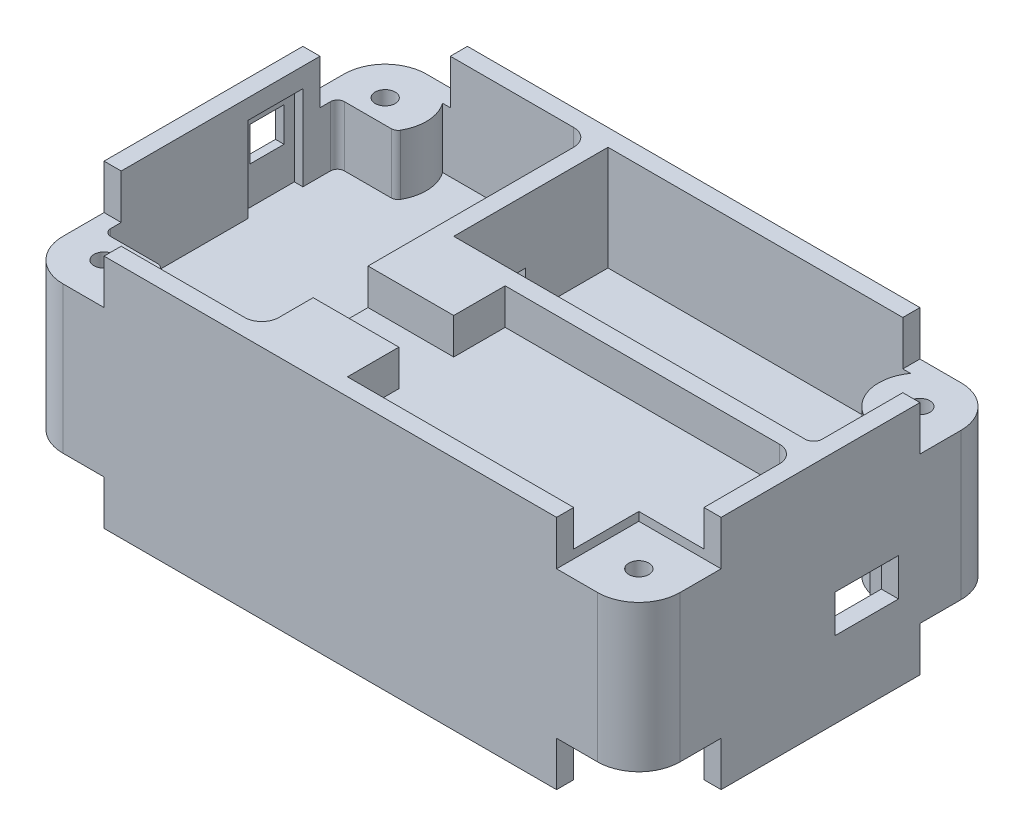
from build123d import *

# Parameters (mm, degrees)
SKETCH1_W                 = 114.3
SKETCH1_H                 = 67.31
SKETCH1_W_2               = 107.95
SKETCH1_H_2               = 60.96
BOSS_EXTRUDE1_DEPTH       = 16.764
BOSS_EXTRUDE1_DEPTH_BACK  = 26.924
FILLET2_R                 = 7.62
BOSS_EXTRUDE3_START       = -26.924
BOSS_EXTRUDE3_DEPTH       = 43.688
BOSS_EXTRUDE4_START       = -26.924
BOSS_EXTRUDE4_DEPTH       = 43.688
BOSS_EXTRUDE5_START       = -26.924
BOSS_EXTRUDE5_DEPTH       = 43.688
BOSS_EXTRUDE6_START       = -26.924
BOSS_EXTRUDE6_DEPTH       = 43.688
BOSS_EXTRUDE7_DEPTH       = 19.3675
BOSS_EXTRUDE8_DEPTH       = 3.175
BOSS_EXTRUDE9_DEPTH       = 3.175
CUT_EXTRUDE7_REACH        = 36.925
SKETCH19_R                = 3.175
SKETCH25_W                = 34.6075
SKETCH25_H                = 3.175
BOSS_EXTRUDE14_DEPTH      = 3.175
SKETCH30_W                = 3.175
SKETCH30_H                = 22.86
BOSS_EXTRUDE22_DEPTH      = 1.5875
BOSS_EXTRUDE22_DEPTH_BACK = 1.5875
SKETCH31_W                = 31.75
SKETCH31_H                = 3.175
BOSS_EXTRUDE23_DEPTH      = 1.5875
SKETCH32_W                = 8.89
SKETCH32_H                = 29.21
BOSS_EXTRUDE24_DEPTH      = 3.175
BOSS_EXTRUDE27_DEPTH      = 3.175
SKETCH38_W                = 13.6525
SKETCH38_H                = 9.525
BOSS_EXTRUDE28_DEPTH      = 6.6675
SKETCH39_W                = 13.6525
SKETCH39_H                = 9.525
BOSS_EXTRUDE29_DEPTH      = 6.6675
FILLET17_R                = 3.175
FILLET18_R                = 1.5875
FILLET22_R                = 3.175
FILLET29_R                = 3.175
SKETCH44_W                = 19.685
SKETCH44_H                = 1.7018
CUT_EXTRUDE13_DEPTH       = 2.54
CUT_EXTRUDE13_DEPTH_BACK  = 1.5875
CUT_EXTRUDE15_REACH       = 116.3
SKETCH46_W                = 11.7475
SKETCH46_H                = 6.985
BOSS_EXTRUDE31_REACH      = 26.13
SKETCH47_W                = 1.5875
SKETCH47_H                = 19.685
SKETCH55_W                = 8.89
SKETCH55_H                = 9.525
BOSS_EXTRUDE32_DEPTH      = 9.8425
SKETCH56_W                = 34.6075
SKETCH56_H                = 3.96875
CUT_EXTRUDE21_DEPTH       = 6.35
SKETCH61_R                = 7.62
BOSS_EXTRUDE35_DEPTH      = 43.688
BOSS_EXTRUDE37_START      = -1.5875
SKETCH63_W                = 6.0325
SKETCH63_H                = 2.54
BOSS_EXTRUDE37_DEPTH      = 21.1455
SKETCH64_W                = 10.16
SKETCH64_H                = 6.35
BOSS_EXTRUDE38_DEPTH      = 3.175
SKETCH65_W                = 6.35
SKETCH65_H                = 6.35
BOSS_EXTRUDE39_DEPTH      = 3.175
SKETCH66_W                = 15.24
SKETCH66_H                = 15.24
CUT_EXTRUDE23_DEPTH       = 3.175
SKETCH67_W                = 15.24
SKETCH67_H                = 15.24
CUT_EXTRUDE24_DEPTH       = 3.175
SKETCH68_W                = 15.24
SKETCH68_H                = 15.24
CUT_EXTRUDE25_DEPTH       = 3.175
SKETCH69_W                = 15.24
SKETCH69_H                = 15.24
CUT_EXTRUDE26_DEPTH       = 3.175
SKETCH70_W                = 15.24
SKETCH70_H                = 15.24
CUT_EXTRUDE27_DEPTH       = 3.175
SKETCH71_W                = 15.24
SKETCH71_H                = 15.24
CUT_EXTRUDE28_DEPTH       = 3.175
SKETCH72_W                = 15.24
SKETCH72_H                = 15.24
CUT_EXTRUDE29_DEPTH       = 3.175
SKETCH73_W                = 15.24
SKETCH73_H                = 15.24
CUT_EXTRUDE30_DEPTH       = 3.175
SKETCH74_R                = 1.8542
CUT_EXTRUDE31_DEPTH       = 41.513
BOSS_EXTRUDE40_DEPTH      = 8.89
SKETCH76_W                = 19.3675
SKETCH76_H                = 29.21
CUT_EXTRUDE32_DEPTH       = 6.6675
SKETCH80_W                = 12.7
SKETCH80_H                = 9.525
BOSS_EXTRUDE41_DEPTH      = 6.6675
SKETCH81_W                = 12.7
SKETCH81_H                = 9.525
BOSS_EXTRUDE42_DEPTH      = 6.6675
SKETCH82_W                = 10.16
SKETCH82_H                = 15.748
CUT_EXTRUDE34_DEPTH       = 1.5875
SKETCH83_W                = 6.35
SKETCH83_H                = 6.35
CUT_EXTRUDE35_DEPTH       = 2.5875
SKETCH88_W                = 5.08
SKETCH88_H                = 29.21
BOSS_EXTRUDE43_DEPTH      = 4.365625
FILLET32_R                = 3.175
FILLET33_R                = 3.175
SKETCH89_W                = 12.7
SKETCH89_H                = 43.2816
CUT_EXTRUDE40_DEPTH       = 16.1925
FILLET34_R                = 1.27
FILLET35_R                = 1.27
CUT_EXTRUDE41_REACH       = 67.405
SKETCH90_R                = 3.33375
SKETCH91_W                = 34.6075
SKETCH91_H                = 3.96875
CUT_EXTRUDE42_DEPTH       = 3.175
SKETCH92_W                = 6.35
SKETCH92_H                = 3.556
BOSS_EXTRUDE44_DEPTH      = 5.08
SKETCH94_W                = 12.7
SKETCH94_H                = 43.2816
CUT_EXTRUDE43_DEPTH       = 17.9705
FILLET36_R                = 1.27
SKETCH95_W                = 7.62
SKETCH95_H                = 7.62
CUT_EXTRUDE44_DEPTH       = 11.43
SKETCH97_W                = 7.62
SKETCH97_H                = 7.62
CUT_EXTRUDE45_DEPTH       = 11.43
SKETCH98_W                = 15.24
SKETCH98_H                = 15.24
CUT_EXTRUDE46_DEPTH       = 5.08
SKETCH99_W                = 15.24
SKETCH99_H                = 15.24
CUT_EXTRUDE47_DEPTH       = 5.08
SKETCH100_W               = 15.24
SKETCH100_H               = 15.24
CUT_EXTRUDE50_DEPTH       = 5.08
SKETCH102_W               = 15.24
SKETCH102_H               = 15.24
CUT_EXTRUDE51_DEPTH       = 5.08
SKETCH103_W               = 15.24
SKETCH103_H               = 15.24
CUT_EXTRUDE52_DEPTH       = 5.08


with BuildPart() as part:
    # Sketch1 → Boss-Extrude1 (new body, two sides)
    with BuildSketch(Plane(origin=(0, 0, 0), x_dir=(1, 0, 0), z_dir=(0, 1, 0))) as boss_extrude1_sk:
        Rectangle(SKETCH1_W, SKETCH1_H)
        Rectangle(SKETCH1_W_2, SKETCH1_H_2, mode=Mode.SUBTRACT)
    extrude(amount=BOSS_EXTRUDE1_DEPTH)
    extrude(boss_extrude1_sk.sketch, amount=-BOSS_EXTRUDE1_DEPTH_BACK)

    # Fillet2
    fillet2_edges = [part.edges().sort_by_distance(p)[0] for p in [
        (57.15, -5.08, 33.655),
        (-57.15, -5.08, 33.655),
        (-57.15, -5.08, -33.655),
        (57.15, -5.08, -33.655),
    ]]
    fillet(fillet2_edges, radius=FILLET2_R)

    # Sketch3 → Boss-Extrude3 (add)
    with BuildSketch(Plane(origin=(0, 0, 0), x_dir=(1, 0, 0), z_dir=(0, 1, 0)).offset(BOSS_EXTRUDE3_START)):
        Polygon((-53.975, 20.32), (-43.815, 30.48), (-53.975, 30.48), align=None)
    extrude(amount=BOSS_EXTRUDE3_DEPTH)

    # Sketch5 → Boss-Extrude4 (add)
    with BuildSketch(Plane(origin=(0, 0, 0), x_dir=(1, 0, 0), z_dir=(0, 1, 0)).offset(BOSS_EXTRUDE4_START)):
        Polygon((-53.975, -30.48), (-53.975, -20.32), (-43.815, -30.48), align=None)
    extrude(amount=BOSS_EXTRUDE4_DEPTH)

    # Sketch6 → Boss-Extrude5 (add)
    with BuildSketch(Plane(origin=(0, 0, 0), x_dir=(1, 0, 0), z_dir=(0, 1, 0)).offset(BOSS_EXTRUDE5_START)):
        Polygon((53.975, -20.32), (43.815, -30.48), (53.975, -30.48), align=None)
    extrude(amount=BOSS_EXTRUDE5_DEPTH)

    # Sketch7 → Boss-Extrude6 (add)
    with BuildSketch(Plane(origin=(0, 0, 0), x_dir=(1, 0, 0), z_dir=(0, 1, 0)).offset(BOSS_EXTRUDE6_START)):
        Polygon((53.975, 30.48), (43.815, 30.48), (53.975, 20.32), align=None)
    extrude(amount=BOSS_EXTRUDE6_DEPTH)

    # Sketch12 → Boss-Extrude7 (add)
    with BuildSketch(Plane(origin=(0, -2.6035, 0), x_dir=(1, 0, 0), z_dir=(0, 1, 0))):
        Polygon((53.975, 1.905), (-12.7, 1.905), (-12.7, 30.48), (-15.875, 30.48), (-15.875, -1.27), (53.975, -1.27), align=None)
    extrude(amount=BOSS_EXTRUDE7_DEPTH)

    # Sketch13 → Boss-Extrude8 (add)
    with BuildSketch(Plane(origin=(0, -2.6035, 0), x_dir=(1, 0, 0), z_dir=(0, 1, 0))):
        with BuildLine():
            Line((-15.875, 30.48), (-15.875, -1.27))
            Line((-15.875, -1.27), (53.975, -1.27))
            Line((53.975, -1.27), (53.975, 17.163692655))
            ThreePointArc((53.975, 17.163692655), (53.394962038, 20.079740409), (51.743153673, 22.551846327))
            Line((51.743153673, 22.551846327), (46.046846327, 28.248153673))
            ThreePointArc((46.046846327, 28.248153673), (43.574740409, 29.899962038), (40.658692655, 30.48))
            Line((40.658692655, 30.48), (-15.875, 30.48))
        make_face()
    extrude(amount=-BOSS_EXTRUDE8_DEPTH)

    # Sketch16 → Boss-Extrude9 (add)
    with BuildSketch(Plane.XZ.offset(5.7785)):
        with BuildLine():
            Line((-15.875, -30.48), (-15.875, 30.48))
            Line((-15.875, 30.48), (-40.658692655, 30.48))
            ThreePointArc((-40.658692655, 30.48), (-43.574740409, 29.899962038), (-46.046846327, 28.248153673))
            Line((-46.046846327, 28.248153673), (-51.743153673, 22.551846327))
            ThreePointArc((-51.743153673, 22.551846327), (-53.394962038, 20.079740409), (-53.975, 17.163692655))
            Line((-53.975, 17.163692655), (-53.975, -17.163692655))
            ThreePointArc((-53.975, -17.163692655), (-53.394962038, -20.079740409), (-51.743153673, -22.551846327))
            Line((-51.743153673, -22.551846327), (-46.046846327, -28.248153673))
            ThreePointArc((-46.046846327, -28.248153673), (-43.574740409, -29.899962038), (-40.658692655, -30.48))
            Line((-40.658692655, -30.48), (-15.875, -30.48))
        make_face()
    extrude(amount=-BOSS_EXTRUDE9_DEPTH)

    # Sketch19 → Cut-Extrude7 (cut, up to next)
    with BuildSketch(Plane.XY.offset(1.27), mode=Mode.PRIVATE) as cut_extrude7_sk1:
        with Locations((41.275, 1.524)):
            Circle(SKETCH19_R)
    cut_extrude7_tool1 = extrude(cut_extrude7_sk1.sketch, amount=-CUT_EXTRUDE7_REACH, mode=Mode.PRIVATE) & part.part
    add(cut_extrude7_tool1.solids().sort_by_distance((41.275, 1.524, 1.27))[0], mode=Mode.SUBTRACT)

    # Sketch25 → Boss-Extrude14 (add)
    with BuildSketch(Plane.XY.offset(1.27)):
        with Locations((36.67125, -5.7785)):
            Rectangle(SKETCH25_W, SKETCH25_H)
    extrude(amount=BOSS_EXTRUDE14_DEPTH)

    # Sketch30 → Boss-Extrude22 (add, two sides)
    with BuildSketch(Plane.XZ.offset(5.7785)) as boss_extrude22_sk:
        with Locations((17.78, -6.985)):
            Rectangle(SKETCH30_W, SKETCH30_H)
    extrude(amount=BOSS_EXTRUDE22_DEPTH)
    extrude(boss_extrude22_sk.sketch, amount=-BOSS_EXTRUDE22_DEPTH_BACK)

    # Sketch31 → Boss-Extrude23 (add)
    with BuildSketch(Plane.XZ.offset(5.7785)):
        with Locations((32.0675, -20.0025)):
            Rectangle(SKETCH31_W, SKETCH31_H)
    extrude(amount=BOSS_EXTRUDE23_DEPTH)

    # Sketch32 → Boss-Extrude24 (add)
    with BuildSketch(Plane.XZ.offset(5.7785)):
        with Locations((-11.43, 15.875)):
            Rectangle(SKETCH32_W, SKETCH32_H)
    extrude(amount=-BOSS_EXTRUDE24_DEPTH)

    # Sketch37 → Boss-Extrude27 (add)
    with BuildSketch(Plane(origin=(0, 10.0965, 0), x_dir=(1, 0, 0), z_dir=(0, 1, 0))):
        Polygon((-6.985, -1.27), (-6.985, -30.48), (43.815, -30.48), (53.975, -20.32), (53.975, -1.27), align=None)
    extrude(amount=-BOSS_EXTRUDE27_DEPTH)

    # Sketch38 → Boss-Extrude28 (add)
    with BuildSketch(Plane(origin=(0, 10.0965, 0), x_dir=(1, 0, 0), z_dir=(0, 1, 0))):
        with Locations((-0.15875, -6.0325)):
            Rectangle(SKETCH38_W, SKETCH38_H)
    extrude(amount=BOSS_EXTRUDE28_DEPTH)

    # Sketch39 → Boss-Extrude29 (add)
    with BuildSketch(Plane(origin=(0, 10.0965, 0), x_dir=(1, 0, 0), z_dir=(0, 1, 0))):
        with Locations((-0.15875, -25.7175)):
            Rectangle(SKETCH39_W, SKETCH39_H)
    extrude(amount=BOSS_EXTRUDE29_DEPTH)

    # Fillet17
    fillet17_edges = [part.edges().sort_by_distance(p)[0] for p in [
        (53.975, 13.43025, 1.27),
    ]]
    fillet(fillet17_edges, radius=FILLET17_R)

    # Fillet18
    fillet18_edges = [part.edges().sort_by_distance(p)[0] for p in [
        (53.975, 7.08025, -1.905),
    ]]
    fillet(fillet18_edges, radius=FILLET18_R)

    # Fillet22
    fillet22_edges = [part.edges().sort_by_distance(p)[0] for p in [
        (-6.985, -4.191, 30.48),
        (-6.985, -4.191, 1.27),
    ]]
    fillet(fillet22_edges, radius=FILLET22_R)

    # Fillet29
    fillet29_edges = [part.edges().sort_by_distance(p)[0] for p in [
        (-15.875, 7.08025, -30.48),
    ]]
    fillet(fillet29_edges, radius=FILLET29_R)

    # Sketch44 → Cut-Extrude13 (cut, two sides)
    with BuildSketch(Plane.ZY.offset(-53.975)) as cut_extrude13_sk:
        with Locations((-8.5725, -6.6294)):
            Rectangle(SKETCH44_W, SKETCH44_H)
    extrude(amount=CUT_EXTRUDE13_DEPTH, mode=Mode.SUBTRACT)
    extrude(cut_extrude13_sk.sketch, amount=-CUT_EXTRUDE13_DEPTH_BACK, mode=Mode.SUBTRACT)

    # Sketch46 → Cut-Extrude15 (cut, up to next)
    with BuildSketch(Plane(origin=(57.15, 0, 0), x_dir=(0, 0, -1), z_dir=(1, 0, 0)), mode=Mode.PRIVATE) as cut_extrude15_sk1:
        with Locations((8.5725, -9.271)):
            Rectangle(SKETCH46_W, SKETCH46_H)
    cut_extrude15_tool1 = extrude(cut_extrude15_sk1.sketch, amount=-CUT_EXTRUDE15_REACH, mode=Mode.PRIVATE) & part.part
    add(cut_extrude15_tool1.solids().sort_by_distance((57.15, -9.271, -8.5725))[0], mode=Mode.SUBTRACT)

    # Sketch47 → Boss-Extrude31 (add, up to next)
    with BuildSketch(Plane.XZ.offset(7.366), mode=Mode.PRIVATE) as boss_extrude31_sk1:
        with Locations((20.16125, -8.5725)):
            Rectangle(SKETCH47_W, SKETCH47_H)
    boss_extrude31_tool1 = extrude(boss_extrude31_sk1.sketch, amount=-BOSS_EXTRUDE31_REACH, mode=Mode.PRIVATE) - part.part
    add(boss_extrude31_tool1.solids().sort_by_distance((20.16125, -7.366, -8.5725))[0])

    # Sketch55 → Boss-Extrude32 (add)
    with BuildSketch(Plane(origin=(0, 16.764, 0), x_dir=(1, 0, 0), z_dir=(0, 1, 0))):
        with Locations((-11.43, -6.0325)):
            Rectangle(SKETCH55_W, SKETCH55_H)
    extrude(amount=-BOSS_EXTRUDE32_DEPTH)

    # Sketch56 → Cut-Extrude21 (cut)
    with BuildSketch(Plane.XZ.offset(5.7785)):
        with Locations((38.25875, -0.714375)):
            Rectangle(SKETCH56_W, SKETCH56_H)
    extrude(amount=-CUT_EXTRUDE21_DEPTH, mode=Mode.SUBTRACT)

    # Sketch61 → Boss-Extrude35 (add)
    with BuildSketch(Plane.XZ.offset(26.924)):
        with Locations((49.53, -26.035)):
            Circle(SKETCH61_R)
        with Locations((49.53, 26.035)):
            Circle(SKETCH61_R)
        with Locations((-49.53, 26.035)):
            Circle(SKETCH61_R)
        with Locations((-49.53, -26.035)):
            Circle(SKETCH61_R)
    extrude(amount=-BOSS_EXTRUDE35_DEPTH)

    # Sketch63 → Boss-Extrude37 (add)
    with BuildSketch(Plane.XZ.offset(7.366).offset(BOSS_EXTRUDE37_START)):
        with Locations((50.95875, -19.685)):
            Rectangle(SKETCH63_W, SKETCH63_H)
    extrude(amount=BOSS_EXTRUDE37_DEPTH)

    # Sketch64 → Boss-Extrude38 (add)
    with BuildSketch(Plane(origin=(0, -2.6035, 0), x_dir=(1, 0, 0), z_dir=(0, 1, 0))):
        with Locations((38.260785591, 27.305)):
            Rectangle(SKETCH64_W, SKETCH64_H)
    extrude(amount=-BOSS_EXTRUDE38_DEPTH)

    # Sketch65 → Boss-Extrude39 (add)
    with BuildSketch(Plane.XZ.offset(5.7785)):
        with Locations((-42.545, 27.305)):
            Rectangle(SKETCH65_W, SKETCH65_H)
        with Locations((-50.8, 17.78)):
            Rectangle(SKETCH65_W, SKETCH65_H)
        with Locations((-50.8, -17.78)):
            Rectangle(SKETCH65_W, SKETCH65_H)
        with Locations((-42.545, -27.305)):
            Rectangle(SKETCH65_W, SKETCH65_H)
    extrude(amount=-BOSS_EXTRUDE39_DEPTH)

    # Sketch66 → Cut-Extrude23 (cut)
    with BuildSketch(Plane.XZ.offset(26.924)):
        with Locations((-49.53, -26.035)):
            Rectangle(SKETCH66_W, SKETCH66_H)
    extrude(amount=-CUT_EXTRUDE23_DEPTH, mode=Mode.SUBTRACT)

    # Sketch67 → Cut-Extrude24 (cut)
    with BuildSketch(Plane.XZ.offset(26.924)):
        with Locations((-49.53, 26.035)):
            Rectangle(SKETCH67_W, SKETCH67_H)
    extrude(amount=-CUT_EXTRUDE24_DEPTH, mode=Mode.SUBTRACT)

    # Sketch68 → Cut-Extrude25 (cut)
    with BuildSketch(Plane.XZ.offset(26.924)):
        with Locations((49.53, -26.035)):
            Rectangle(SKETCH68_W, SKETCH68_H)
    extrude(amount=-CUT_EXTRUDE25_DEPTH, mode=Mode.SUBTRACT)

    # Sketch69 → Cut-Extrude26 (cut)
    with BuildSketch(Plane.XZ.offset(26.924)):
        with Locations((49.53, 26.035)):
            Rectangle(SKETCH69_W, SKETCH69_H)
    extrude(amount=-CUT_EXTRUDE26_DEPTH, mode=Mode.SUBTRACT)

    # Sketch70 → Cut-Extrude27 (cut)
    with BuildSketch(Plane(origin=(0, 16.764, 0), x_dir=(1, 0, 0), z_dir=(0, 1, 0))):
        with Locations((-49.53, 26.035)):
            Rectangle(SKETCH70_W, SKETCH70_H)
    extrude(amount=-CUT_EXTRUDE27_DEPTH, mode=Mode.SUBTRACT)

    # Sketch71 → Cut-Extrude28 (cut)
    with BuildSketch(Plane(origin=(0, 16.764, 0), x_dir=(1, 0, 0), z_dir=(0, 1, 0))):
        with Locations((-49.53, -26.035)):
            Rectangle(SKETCH71_W, SKETCH71_H)
    extrude(amount=-CUT_EXTRUDE28_DEPTH, mode=Mode.SUBTRACT)

    # Sketch72 → Cut-Extrude29 (cut)
    with BuildSketch(Plane(origin=(0, 16.764, 0), x_dir=(1, 0, 0), z_dir=(0, 1, 0))):
        with Locations((49.53, -26.035)):
            Rectangle(SKETCH72_W, SKETCH72_H)
    extrude(amount=-CUT_EXTRUDE29_DEPTH, mode=Mode.SUBTRACT)

    # Sketch73 → Cut-Extrude30 (cut)
    with BuildSketch(Plane(origin=(0, 16.764, 0), x_dir=(1, 0, 0), z_dir=(0, 1, 0))):
        with Locations((49.53, 26.035)):
            Rectangle(SKETCH73_W, SKETCH73_H)
    extrude(amount=-CUT_EXTRUDE30_DEPTH, mode=Mode.SUBTRACT)

    # Sketch74 → Cut-Extrude31 (cut, through all)
    with BuildSketch(Plane(origin=(0, 13.589, 0), x_dir=(1, 0, 0), z_dir=(0, 1, 0))):
        with Locations(Location((-49.53, 26.035, 0), (0, 0, 270))):  # turned: the seam where the file's is
            Circle(SKETCH74_R)
        with Locations(Location((49.53, 26.035, 0), (0, 0, 270))):  # turned: the seam where the file's is
            Circle(SKETCH74_R)
        with Locations(Location((49.53, -26.035, 0), (0, 0, 270))):  # turned: the seam where the file's is
            Circle(SKETCH74_R)
        with Locations(Location((-49.53, -26.035, 0), (0, 0, 270))):  # turned: the seam where the file's is
            Circle(SKETCH74_R)
    extrude(amount=-CUT_EXTRUDE31_DEPTH, mode=Mode.SUBTRACT)

    # Sketch75 → Boss-Extrude40 (add)
    with BuildSketch(Plane.ZY.offset(6.985)):
        Polygon((10.795, 10.0965), (10.795, 6.9215), (30.48, 6.9215), (30.48, 16.764), (20.955, 16.764), (20.955, 10.0965), align=None)
    extrude(amount=BOSS_EXTRUDE40_DEPTH)

    # Sketch76 → Cut-Extrude32 (cut)
    with BuildSketch(Plane(origin=(0, 16.764, 0), x_dir=(1, 0, 0), z_dir=(0, 1, 0))):
        with Locations((-3.01625, -15.875)):
            Rectangle(SKETCH76_W, SKETCH76_H)
    extrude(amount=-CUT_EXTRUDE32_DEPTH, mode=Mode.SUBTRACT)

    # Sketch80 → Boss-Extrude41 (add)
    with BuildSketch(Plane(origin=(0, 16.764, 0), x_dir=(1, 0, 0), z_dir=(0, 1, 0))):
        with Locations((-6.35, -6.0325)):
            Rectangle(SKETCH80_W, SKETCH80_H)
    extrude(amount=-BOSS_EXTRUDE41_DEPTH)

    # Sketch81 → Boss-Extrude42 (add)
    with BuildSketch(Plane(origin=(0, 16.764, 0), x_dir=(1, 0, 0), z_dir=(0, 1, 0))):
        with Locations((-6.35, -25.7175)):
            Rectangle(SKETCH81_W, SKETCH81_H)
    extrude(amount=-BOSS_EXTRUDE42_DEPTH)

    # Sketch82 → Cut-Extrude34 (cut)
    with BuildSketch(Plane(origin=(-53.975, 0, 0), x_dir=(0, 0, -1), z_dir=(1, 0, 0))):
        with Locations((10.16, 5.2705)):
            Rectangle(SKETCH82_W, SKETCH82_H)
    extrude(amount=-CUT_EXTRUDE34_DEPTH, mode=Mode.SUBTRACT)

    # Sketch83 → Cut-Extrude35 (cut, through all)
    with BuildSketch(Plane(origin=(-55.5625, 0, 0), x_dir=(0, 0, -1), z_dir=(1, 0, 0))):
        with Locations((10.16, 7.5565)):
            Rectangle(SKETCH83_W, SKETCH83_H)
    extrude(amount=-CUT_EXTRUDE35_DEPTH, mode=Mode.SUBTRACT)

    # Sketch88 → Boss-Extrude43 (add)
    with BuildSketch(Plane.XZ.offset(-6.9215)):
        with Locations((5.715, 15.875)):
            Rectangle(SKETCH88_W, SKETCH88_H)
    extrude(amount=BOSS_EXTRUDE43_DEPTH)

    # Fillet32
    fillet32_edges = [part.edges().sort_by_distance(p)[0] for p in [
        (-15.875, 11.84275, 30.48),
    ]]
    fillet(fillet32_edges, radius=FILLET32_R)

    # Fillet33
    fillet33_edges = [part.edges().sort_by_distance(p)[0] for p in [
        (-15.875, 2.159, 1.27),
    ]]
    fillet(fillet33_edges, radius=FILLET33_R)

    # Sketch89 → Cut-Extrude40 (cut)
    with BuildSketch(Plane(origin=(0, 13.589, 0), x_dir=(1, 0, 0), z_dir=(0, 1, 0))):
        with Locations((-47.625, 0)):
            Rectangle(SKETCH89_W, SKETCH89_H)
    extrude(amount=-CUT_EXTRUDE40_DEPTH, mode=Mode.SUBTRACT)

    # Fillet34
    fillet34_edges = [part.edges().sort_by_distance(p)[0] for p in [
        (-53.975, 5.49275, 21.6408),
        (-53.975, 5.49275, -21.6408),
    ]]
    fillet(fillet34_edges, radius=FILLET34_R)

    # Fillet35
    fillet35_edges = [part.edges().sort_by_distance(p)[0] for p in [
        (-43.304615967, 5.49275, -21.6408),
        (-43.304615967, 5.49275, 21.6408),
    ]]
    fillet(fillet35_edges, radius=FILLET35_R)

    # Sketch90 → Cut-Extrude41 (cut, up to next)
    with BuildSketch(Plane(origin=(8.255, 0, 0), x_dir=(0, 0, -1), z_dir=(1, 0, 0)), mode=Mode.PRIVATE) as cut_extrude41_sk1:
        with Locations((-12.22375, 2.555875)):
            Circle(SKETCH90_R)
    cut_extrude41_tool1 = extrude(cut_extrude41_sk1.sketch, amount=-CUT_EXTRUDE41_REACH, mode=Mode.PRIVATE) & part.part
    add(cut_extrude41_tool1.solids().sort_by_distance((8.255, 2.555875, 12.22375))[0], mode=Mode.SUBTRACT)

    # Sketch91 → Cut-Extrude42 (cut)
    with BuildSketch(Plane.XZ.offset(5.7785)):
        with Locations((38.25875, -16.430625)):
            Rectangle(SKETCH91_W, SKETCH91_H)
    extrude(amount=-CUT_EXTRUDE42_DEPTH, mode=Mode.SUBTRACT)

    # Sketch92 → Boss-Extrude44 (add)
    with BuildSketch(Plane.XY.offset(-18.415)):
        with Locations((51.59375, -4.3815)):
            Rectangle(SKETCH92_W, SKETCH92_H)
    extrude(amount=-BOSS_EXTRUDE44_DEPTH)

    # Sketch94 → Cut-Extrude43 (cut)
    with BuildSketch(Plane.XZ.offset(23.749)):
        with Locations((-47.625, 0)):
            Rectangle(SKETCH94_W, SKETCH94_H)
    extrude(amount=-CUT_EXTRUDE43_DEPTH, mode=Mode.SUBTRACT)

    # Fillet36
    fillet36_edges = [part.edges().sort_by_distance(p)[0] for p in [
        (-43.304615967, -14.76375, -21.6408),
        (-43.304615967, -14.76375, 21.6408),
        (-53.975, -14.76375, 21.6408),
        (-53.975, -14.76375, -21.6408),
    ]]
    fillet(fillet36_edges, radius=FILLET36_R)

    # Sketch95 → Cut-Extrude44 (cut)
    with BuildSketch(Plane.ZY.offset(15.875)):
        with Locations((-11.4046, 1.2065)):
            Rectangle(SKETCH95_W, SKETCH95_H)
    extrude(amount=-CUT_EXTRUDE44_DEPTH, mode=Mode.SUBTRACT)

    # Sketch97 → Cut-Extrude45 (cut)
    with BuildSketch(Plane.XY.offset(1.27)):
        with Locations((-0.635, 3.1115)):
            Rectangle(SKETCH97_W, SKETCH97_H)
    extrude(amount=-CUT_EXTRUDE45_DEPTH, mode=Mode.SUBTRACT)

    # Sketch98 → Cut-Extrude46 (cut)
    with BuildSketch(Plane.XZ.offset(23.749)):
        with Locations((-49.53, -26.035)):
            Rectangle(SKETCH98_W, SKETCH98_H)
    extrude(amount=-CUT_EXTRUDE46_DEPTH, mode=Mode.SUBTRACT)

    # Sketch99 → Cut-Extrude47 (cut)
    with BuildSketch(Plane.XZ.offset(23.749)):
        with Locations((49.53, -26.035)):
            Rectangle(SKETCH99_W, SKETCH99_H)
    extrude(amount=-CUT_EXTRUDE47_DEPTH, mode=Mode.SUBTRACT)

    # Sketch100 → Cut-Extrude50 (cut)
    with BuildSketch(Plane.XZ.offset(23.749)):
        with Locations((49.53, 26.035)):
            Rectangle(SKETCH100_W, SKETCH100_H)
    extrude(amount=-CUT_EXTRUDE50_DEPTH, mode=Mode.SUBTRACT)

    # Sketch102 → Cut-Extrude51 (cut)
    with BuildSketch(Plane.XZ.offset(23.749)):
        with Locations((-49.53, 26.035)):
            Rectangle(SKETCH102_W, SKETCH102_H)
    extrude(amount=-CUT_EXTRUDE51_DEPTH, mode=Mode.SUBTRACT)

    # Sketch103 → Cut-Extrude52 (cut)
    with BuildSketch(Plane(origin=(0, 13.589, 0), x_dir=(1, 0, 0), z_dir=(0, 1, 0))):
        with Locations((-49.53, -26.035)):
            Rectangle(SKETCH103_W, SKETCH103_H)
        with Locations((-49.53, 26.035)):
            Rectangle(SKETCH103_W, SKETCH103_H)
        with Locations((49.53, 26.035)):
            Rectangle(SKETCH103_W, SKETCH103_H)
        with Locations((49.53, -26.035)):
            Rectangle(SKETCH103_W, SKETCH103_H)
    extrude(amount=-CUT_EXTRUDE52_DEPTH, mode=Mode.SUBTRACT)


solid = part.part
